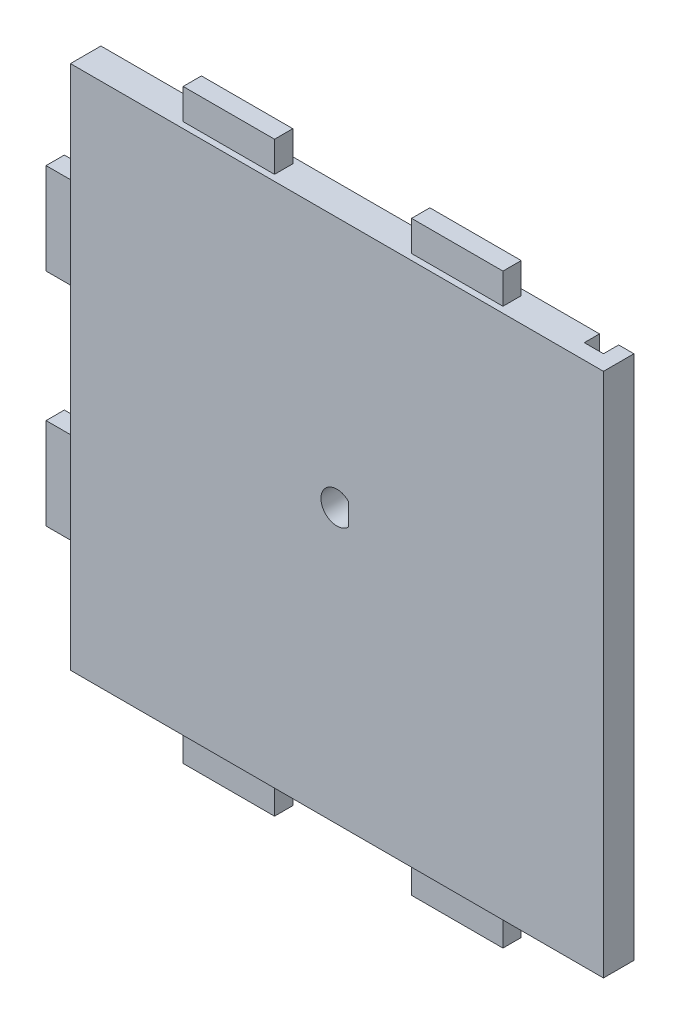
from build123d import *

# Parameters (mm, degrees)
ESBO_O1_W                = 175
ESBO_O1_H                = 172.5
RESSALTO_EXTRUS_O1_DEPTH = 10
ESBO_O5_W                = 30
ESBO_O5_H                = 6
RESSALTO_EXTRUS_O5_DEPTH = 10
ESBO_O6_W                = 6
ESBO_O6_H                = 30
RESSALTO_EXTRUS_O6_DEPTH = 10
ESBO_O7_W                = 30
ESBO_O7_H                = 6
RESSALTO_EXTRUS_O7_DEPTH = 10
ESBO_O8_W                = 6.3
ESBO_O8_H                = 172.5
CORTE_EXTRUS_O1_DEPTH    = 5
ESBO_O9_R                = 1.5
CORTE_EXTRUS_O2_DEPTH    = 8
ESBO_O10_R               = 1.5
CORTE_EXTRUS_O3_DEPTH    = 8
CORTE_EXTRUS_O4_DEPTH    = 11


with BuildPart() as part:
    # Esboço1 → Ressalto-extrusão1 (new body)
    with BuildSketch(Plane.XY):
        Rectangle(ESBO_O1_W, ESBO_O1_H)
    extrude(amount=RESSALTO_EXTRUS_O1_DEPTH)

    # Esboço5 → Ressalto-extrusão5 (add)
    with BuildSketch(Plane(origin=(0, 86.25, 0), x_dir=(1, 0, 0), z_dir=(0, 1, 0))):
        with Locations((-37.5, -5)):
            Rectangle(ESBO_O5_W, ESBO_O5_H)
        with Locations((37.5, -5)):
            Rectangle(ESBO_O5_W, ESBO_O5_H)
    extrude(amount=RESSALTO_EXTRUS_O5_DEPTH)

    # Esboço6 → Ressalto-extrusão6 (add)
    with BuildSketch(Plane.ZY.offset(87.5)):
        with Locations((5, 36.25)):
            Rectangle(ESBO_O6_W, ESBO_O6_H)
        with Locations((5, -36.25)):
            Rectangle(ESBO_O6_W, ESBO_O6_H)
    extrude(amount=RESSALTO_EXTRUS_O6_DEPTH)

    # Esboço7 → Ressalto-extrusão7 (add)
    with BuildSketch(Plane.XZ.offset(86.25)):
        with Locations((-37.5, 5)):
            Rectangle(ESBO_O7_W, ESBO_O7_H)
        with Locations((37.5, 5)):
            Rectangle(ESBO_O7_W, ESBO_O7_H)
    extrude(amount=RESSALTO_EXTRUS_O7_DEPTH)

    # Esboço8 → Corte-extrusão1 (cut)
    with BuildSketch(Plane(origin=(0, 0, 0), x_dir=(-1, 0, 0), z_dir=(0, 0, -1))):
        with Locations((-79.35, 0)):
            Rectangle(ESBO_O8_W, ESBO_O8_H)
    extrude(amount=-CORTE_EXTRUS_O1_DEPTH, mode=Mode.SUBTRACT)

    # Esboço9 → Corte-extrusão2 (cut)
    with BuildSketch(Plane.ZY.offset(87.5)):
        with Locations((5, -71.25)):
            Circle(ESBO_O9_R)
    extrude(amount=-CORTE_EXTRUS_O2_DEPTH, mode=Mode.SUBTRACT)

    # Esboço10 → Corte-extrusão3 (cut)
    with BuildSketch(Plane.XZ.offset(86.25)):
        with Locations((65, 5)):
            Circle(ESBO_O10_R)
    extrude(amount=-CORTE_EXTRUS_O3_DEPTH, mode=Mode.SUBTRACT)

    # Esboço11 → Corte-extrusão4 (cut, through all)
    with BuildSketch(Plane.XY.offset(10)):
        with BuildLine():
            ThreePointArc((3.85, 7.31931366), (-5.25, 3.75), (3.85, 0.18068634))
            Line((3.85, 0.18068634), (3.85, 7.31931366))
        make_face()
    extrude(amount=-CORTE_EXTRUS_O4_DEPTH, mode=Mode.SUBTRACT)


solid = part.part
